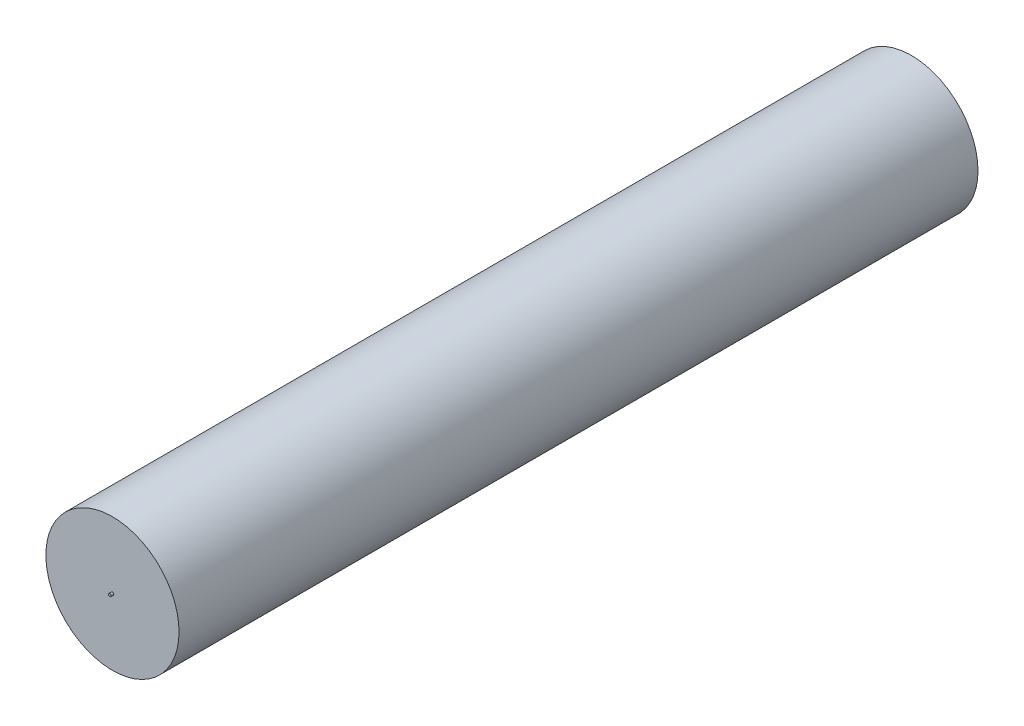
from build123d import *

# Parameters (mm, degrees)
BOSS_EXTRUDE1_DEPTH      = 150
BOSS_EXTRUDE1_DEPTH_BACK = 150
SKETCH1_R                = 25
SKETCH2_R                = 0.5
BOSS_EXTRUDE2_DEPTH      = 1


with BuildPart() as part:
    # Sketch1 → Boss-Extrude1 (new, two sides: drawn at the far end of the back side and taken through both)
    with BuildSketch(Plane.XY.offset(-BOSS_EXTRUDE1_DEPTH_BACK)):
        Circle(SKETCH1_R)
    extrude(amount=BOSS_EXTRUDE1_DEPTH + BOSS_EXTRUDE1_DEPTH_BACK)

    # Sketch2 → Boss-Extrude2 (add)
    with BuildSketch(Plane.XY.offset(150)):
        Circle(SKETCH2_R)
    extrude(amount=BOSS_EXTRUDE2_DEPTH)


solid = part.part
